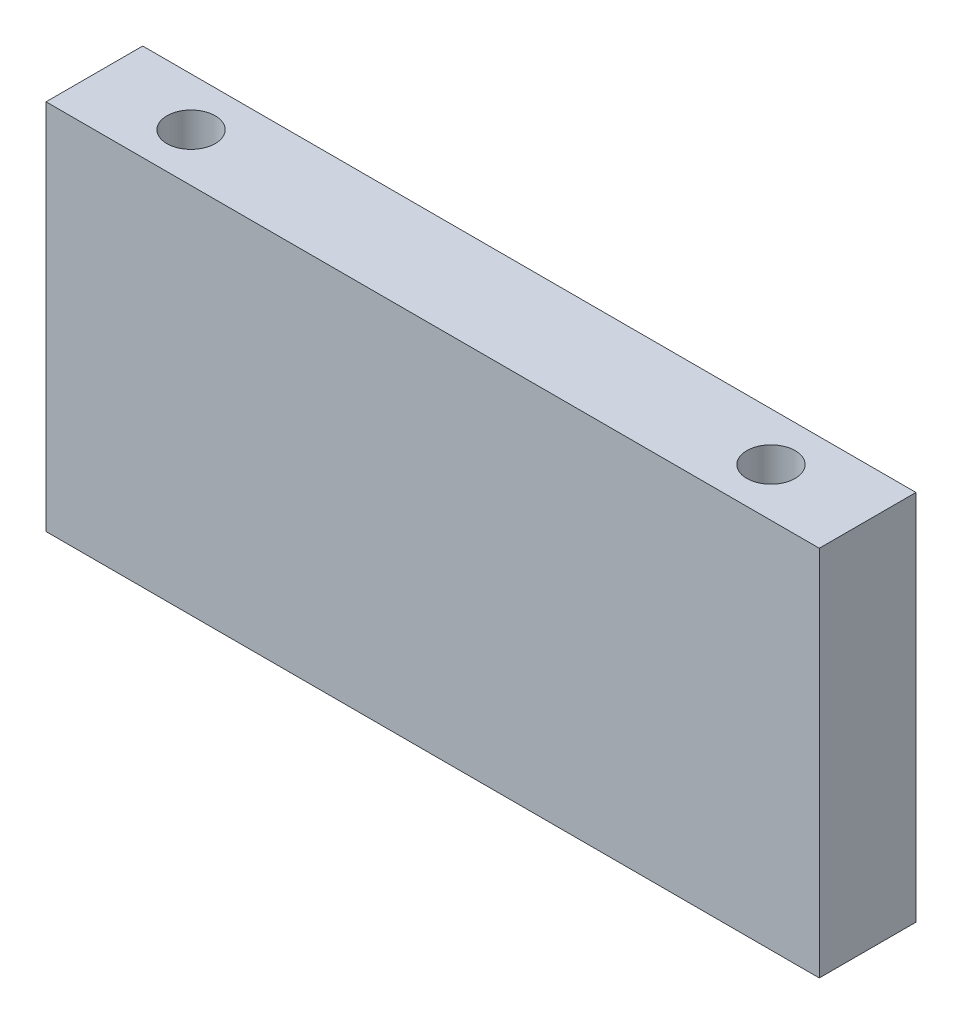
from build123d import *

# Parameters (mm, degrees)
SKETCH1_W           = 152.4
SKETCH1_H           = 19.05
BOSS_EXTRUDE1_DEPTH = 36.6776
SKETCH2_R           = 4.7625
CUT_EXTRUDE1_DEPTH  = 19.05


with BuildPart() as part:
    # Sketch1 → Boss-Extrude1 (new body, symmetric)
    with BuildSketch(Plane(origin=(0, 0, 0), x_dir=(1, 0, 0), z_dir=(0, 1, 0))):
        Rectangle(SKETCH1_W, SKETCH1_H)
    extrude(amount=BOSS_EXTRUDE1_DEPTH, both=True)

    # Sketch2 → Cut-Extrude1 (cut)
    with BuildSketch(Plane(origin=(0, 36.6776, 0), x_dir=(1, 0, 0), z_dir=(0, 1, 0))):
        with Locations((-57.15, 0)):
            Circle(SKETCH2_R)
        with Locations((57.15, 0)):
            Circle(SKETCH2_R)
    cut_extrude1 = extrude(amount=-CUT_EXTRUDE1_DEPTH, mode=Mode.SUBTRACT)

    # Mirror2: Cut-Extrude1 across plane
    add(cut_extrude1.mirror(Plane.ZX), mode=Mode.SUBTRACT)


solid = part.part
